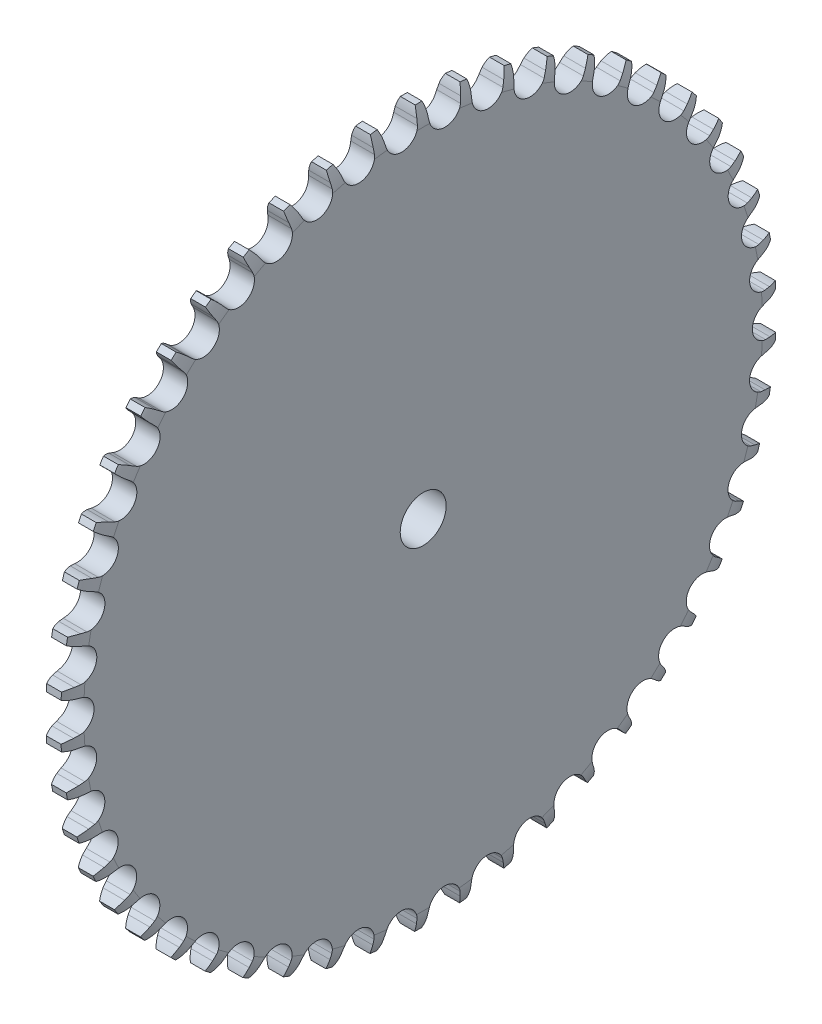
from build123d import *

# Parameters (mm, degrees)
SKETCH2_R           = 5
CUT_EXTRUDE1_DEPTH  = 93
CUT_EXTRUDE2_DEPTH  = 50
CIRPATTERN2_COUNT   = 50
CUT_EXTRUDE3_DEPTH  = 12.85
SKETCH6_R           = 3
CUT_EXTRUDE4_DEPTH  = 4.5
CUT_EXTRUDE5_REACH  = 99.85
SKETCH7_R           = 1.95
SKETCH8_W           = 5.7
SKETCH8_H           = 2.5
CUT_EXTRUDE6_DEPTH  = 17.85
SKETCH9_R           = 3
CUT_EXTRUDE7_DEPTH  = 4.5
CUT_EXTRUDE8_REACH  = 128.252
SKETCH10_R          = 1.95
CUT_EXTRUDE9_REACH  = 128.252
SKETCH11_R          = 1.95
SKETCH12_R          = 3
CUT_EXTRUDE10_DEPTH = 4.5
CUT_EXTRUDE11_REACH = 128.252
SKETCH13_R          = 1.95
CUT_EXTRUDE12_REACH = 128.252
SKETCH14_R          = 1.95


with BuildPart() as part:
    # Sketch1 → Revolve1 (revolve)
    with BuildSketch(Plane.XY):
        with BuildLine():
            Line((0, 0), (0, 73.841409142))
            ThreePointArc((0, 73.841409142), (-0.311316317, 75.900257121), (-1.042257871, 77.85))
            Line((-1.042257871, 77.85), (-4.257742129, 77.85))
            ThreePointArc((-4.257742129, 77.85), (-4.988683683, 75.900257121), (-5.3, 73.841409142))
            Line((-5.3, 73.841409142), (-5.3, 20))
            Line((-5.3, 20), (-35.3, 20))
            Line((-35.3, 20), (-35.3, 0))
            Line((-35.3, 0), (0, 0))
        make_face()
    revolve(axis=Axis((0, 0, 0), (1, 0, 0)))

    # Sketch2 → Cut-Extrude1 (cut)
    with BuildSketch(Plane.ZY.offset(35.3)):
        Circle(SKETCH2_R)
    extrude(amount=-CUT_EXTRUDE1_DEPTH, mode=Mode.SUBTRACT)

    # Sketch4 → Cut-Extrude2 (cut)
    with BuildSketch(Plane.ZY.offset(35.3)):
        with BuildLine():
            Line((-1.1687036, 75.835995127), (-1.276760468, 74.642627583))
            ThreePointArc((-1.276760468, 74.642627583), (-4.540573702, 71.465296795), (-8.180265006, 74.204010904))
            Line((-8.180265006, 74.204010904), (-8.438485392, 75.374106889))
            ThreePointArc((-8.438485392, 75.374106889), (-8.705216664, 76.361937098), (-9.062581418, 77.320709503))
            ThreePointArc((-9.062581418, 77.320709503), (-4.936274948, 77.693343921), (-0.795987661, 77.845930553))
            ThreePointArc((-0.795987661, 77.845930553), (-1.029136754, 76.849639635), (-1.1687036, 75.835995127))
        make_face()
    cut_extrude2 = extrude(amount=-CUT_EXTRUDE2_DEPTH, mode=Mode.SUBTRACT)

    # CirPattern2: Cut-Extrude2 ×50 about axis
    cirpattern2_axis = Axis((0, 0, 0), (1, 0, 0))
    for i in range(1, CIRPATTERN2_COUNT):
        add(cut_extrude2.rotate(cirpattern2_axis, i * 360 / CIRPATTERN2_COUNT), mode=Mode.SUBTRACT)

    # Sketch5 → Cut-Extrude3 (cut)
    with BuildSketch(Plane.ZY.offset(35.3)):
        Polygon((0, 7), (-2.85, 7), (-2.85, 9.5), (2.85, 9.5), (2.85, 7), align=None)
        Polygon((6.062177826, -3.5), (7.487177826, -1.031827599), (9.652241336, -2.281827599), (6.802241336, -7.218172401), (4.637177826, -5.968172401), align=None)
        Polygon((-6.062177826, -3.5), (-7.487177826, -1.031827599), (-9.652241336, -2.281827599), (-6.802241336, -7.218172401), (-4.637177826, -5.968172401), align=None)
    extrude(amount=-CUT_EXTRUDE3_DEPTH, mode=Mode.SUBTRACT)

    # Sketch6 → Cut-Extrude4 (cut)
    with BuildSketch(Plane(origin=(0, 20, 0), x_dir=(1, 0, 0), z_dir=(0, 1, 0))):
        with Locations((-20.3, 0)):
            Circle(SKETCH6_R)
    extrude(amount=-CUT_EXTRUDE4_DEPTH, mode=Mode.SUBTRACT)

    # Sketch7 → Cut-Extrude5 (cut, up to next)
    with BuildSketch(Plane(origin=(0, 20, 0), x_dir=(1, 0, 0), z_dir=(0, 1, 0)), mode=Mode.PRIVATE) as cut_extrude5_sk1:
        with Locations((-20.3, 0)):
            Circle(SKETCH7_R)
    cut_extrude5_tool1 = extrude(cut_extrude5_sk1.sketch, amount=-CUT_EXTRUDE5_REACH, mode=Mode.PRIVATE) & part.part
    add(cut_extrude5_tool1.solids().sort_by_distance((-20.3, 20, 0))[0], mode=Mode.SUBTRACT)

    # Sketch8 → Cut-Extrude6 (cut)
    with BuildSketch(Plane.ZY.offset(35.3)):
        with Locations((0, 8.25)):
            Rectangle(SKETCH8_W, SKETCH8_H)
        Polygon((7.487177826, -1.031827599), (4.637177826, -5.968172401), (6.802241336, -7.218172401), (9.652241336, -2.281827599), align=None)
        Polygon((-7.487177826, -1.031827599), (-9.652241336, -2.281827599), (-6.802241336, -7.218172401), (-4.637177826, -5.968172401), align=None)
    extrude(amount=-CUT_EXTRUDE6_DEPTH, mode=Mode.SUBTRACT)

    # Sketch9 → Cut-Extrude7 (cut)
    with BuildSketch(Plane(origin=(0, -10, 17.320508076), x_dir=(-1, 0, 0), z_dir=(0, -0.5, 0.866025404))):
        with Locations((20.3, 0)):
            Circle(SKETCH9_R)
    extrude(amount=-CUT_EXTRUDE7_DEPTH, mode=Mode.SUBTRACT)

    # Sketch10 → Cut-Extrude8 (cut, up to next)
    with BuildSketch(Plane(origin=(0, -10, 17.320508076), x_dir=(-1, 0, 0), z_dir=(0, -0.5, 0.866025404)), mode=Mode.PRIVATE) as cut_extrude8_sk1:
        with Locations((20.3, 0)):
            Circle(SKETCH10_R)
    cut_extrude8_tool1 = extrude(cut_extrude8_sk1.sketch, amount=-CUT_EXTRUDE8_REACH, mode=Mode.PRIVATE) & part.part
    add(cut_extrude8_tool1.solids().sort_by_distance((-20.3, -10, 17.320508))[0], mode=Mode.SUBTRACT)

    # Sketch11 → Cut-Extrude9 (cut, up to next)
    with BuildSketch(Plane(origin=(0, -10, 17.320508076), x_dir=(-1, 0, 0), z_dir=(0, -0.5, 0.866025404)), mode=Mode.PRIVATE) as cut_extrude9_sk1:
        with Locations((20.3, 0)):
            Circle(SKETCH11_R)
    cut_extrude9_tool1 = extrude(cut_extrude9_sk1.sketch, amount=-CUT_EXTRUDE9_REACH, mode=Mode.PRIVATE) & part.part
    add(cut_extrude9_tool1.solids().sort_by_distance((-20.3, -10, 17.320508))[0], mode=Mode.SUBTRACT)

    # Sketch12 → Cut-Extrude10 (cut)
    with BuildSketch(Plane(origin=(0, -10, -17.320508076), x_dir=(-1, 0, 0), z_dir=(0, -0.5, -0.866025404))):
        with Locations((20.3, 0)):
            Circle(SKETCH12_R)
    extrude(amount=-CUT_EXTRUDE10_DEPTH, mode=Mode.SUBTRACT)

    # Sketch13 → Cut-Extrude11 (cut, up to next)
    with BuildSketch(Plane(origin=(0, -10, -17.320508076), x_dir=(-1, 0, 0), z_dir=(0, -0.5, -0.866025404)), mode=Mode.PRIVATE) as cut_extrude11_sk1:
        with Locations((20.3, 0)):
            Circle(SKETCH13_R)
    cut_extrude11_tool1 = extrude(cut_extrude11_sk1.sketch, amount=-CUT_EXTRUDE11_REACH, mode=Mode.PRIVATE) & part.part
    add(cut_extrude11_tool1.solids().sort_by_distance((-20.3, -10, -17.320508))[0], mode=Mode.SUBTRACT)

    # Sketch14 → Cut-Extrude12 (cut, up to next)
    with BuildSketch(Plane(origin=(0, -10, -17.320508076), x_dir=(-1, 0, 0), z_dir=(0, -0.5, -0.866025404)), mode=Mode.PRIVATE) as cut_extrude12_sk1:
        with Locations((20.3, 0)):
            Circle(SKETCH14_R)
    cut_extrude12_tool1 = extrude(cut_extrude12_sk1.sketch, amount=-CUT_EXTRUDE12_REACH, mode=Mode.PRIVATE) & part.part
    add(cut_extrude12_tool1.solids().sort_by_distance((-20.3, -10, -17.320508))[0], mode=Mode.SUBTRACT)


solid = part.part
